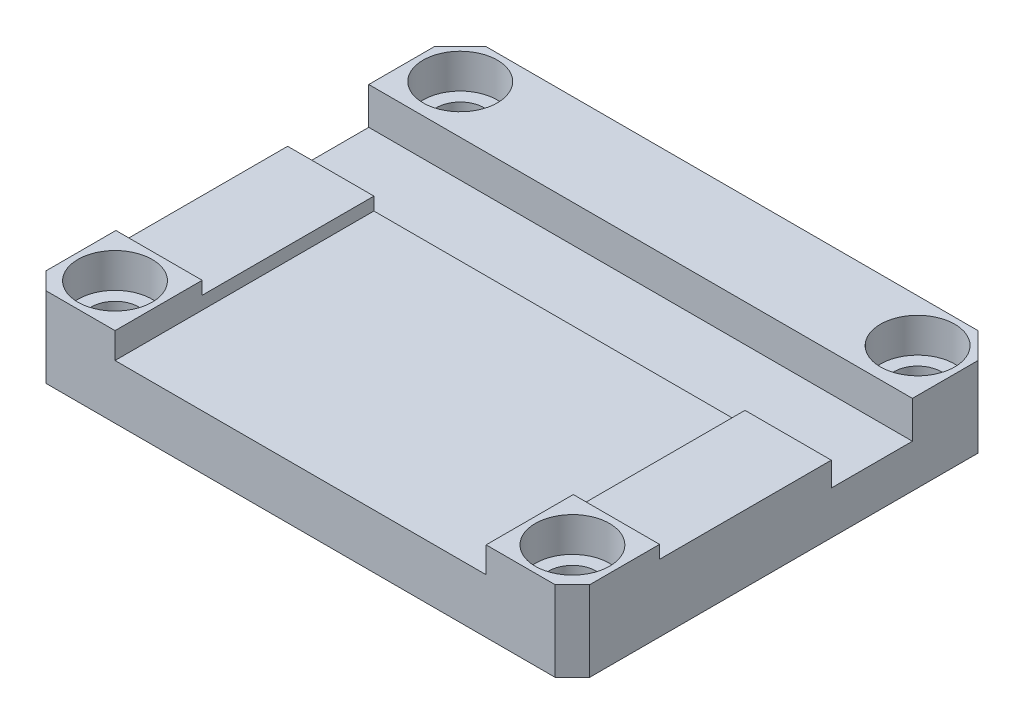
from build123d import *

# Parameters (mm, degrees)
SKETCH1_W                                           = 63
SKETCH1_H                                           = 50
BOSS_EXTRUDE1_DEPTH                                 = 9.3
CBORE_FOR_M5_HEX_SOCKET_HEAD_CAP_SCREW2_D           = 5.5
CBORE_FOR_M5_HEX_SOCKET_HEAD_CAP_SCREW2_CBORE_D     = 8.6
CBORE_FOR_M5_HEX_SOCKET_HEAD_CAP_SCREW2_CBORE_DEPTH = 4
CHAMFER1_SIZE                                       = 3
CHAMFER2_SIZE                                       = 2
CUT_EXTRUDE1_DEPTH                                  = 3
CUT_EXTRUDE2_DEPTH                                  = 4.3
SKETCH8_W                                           = 10
SKETCH8_H                                           = 19.9
CUT_EXTRUDE3_DEPTH                                  = 1.5


with BuildPart() as part:
    # Sketch1 → Boss-Extrude1 (new body)
    with BuildSketch(Plane(origin=(0, 0, 0), x_dir=(1, 0, 0), z_dir=(0, 1, 0))):
        Rectangle(SKETCH1_W, SKETCH1_H)
    extrude(amount=BOSS_EXTRUDE1_DEPTH)

    # CBORE for M5 Hex Socket Head Cap Screw2 (through all)
    with Locations(Plane(origin=(-26.5, 9.3, 20), x_dir=(0, 0, 1), z_dir=(0, 1, 0))):
        with Locations((0, 0), (0, 53), (-40, 53), (-40, 0)):
            CounterBoreHole(CBORE_FOR_M5_HEX_SOCKET_HEAD_CAP_SCREW2_D / 2, CBORE_FOR_M5_HEX_SOCKET_HEAD_CAP_SCREW2_CBORE_D / 2, CBORE_FOR_M5_HEX_SOCKET_HEAD_CAP_SCREW2_CBORE_DEPTH)

    # Chamfer1
    chamfer1_edges = [part.edges().sort_by_distance(p)[0] for p in [
        (-31.5, 4.65, -25),
        (31.5, 4.65, -25),
    ]]
    chamfer(chamfer1_edges, length=CHAMFER1_SIZE)

    # Chamfer2
    chamfer2_edges = [part.edges().sort_by_distance(p)[0] for p in [
        (31.5, 4.65, 25),
        (-31.5, 4.65, 25),
    ]]
    chamfer(chamfer2_edges, length=CHAMFER2_SIZE)

    # Sketch5 → Cut-Extrude1 (cut)
    with BuildSketch(Plane(origin=(0, 9.3, 0), x_dir=(1, 0, 0), z_dir=(0, 1, 0))):
        Polygon((0, -25), (-21.5, -25), (-21.5, 14.4), (21.5, 14.4), (21.5, -25), align=None)
    extrude(amount=-CUT_EXTRUDE1_DEPTH, mode=Mode.SUBTRACT)

    # Sketch7 → Cut-Extrude2 (cut)
    with BuildSketch(Plane(origin=(0, 9.3, 0), x_dir=(1, 0, 0), z_dir=(0, 1, 0))):
        Polygon((-21.5, 14.4), (31.5, 14.4), (31.5, 5), (-31.5, 5), (-31.5, 14.4), align=None)
    extrude(amount=-CUT_EXTRUDE2_DEPTH, mode=Mode.SUBTRACT)

    # Sketch8 → Cut-Extrude3 (cut)
    with BuildSketch(Plane(origin=(0, 9.3, 0), x_dir=(1, 0, 0), z_dir=(0, 1, 0))):
        with Locations((26.5, -4.95)):
            Rectangle(SKETCH8_W, SKETCH8_H)
        with Locations((-26.5, -4.95)):
            Rectangle(SKETCH8_W, SKETCH8_H)
    extrude(amount=-CUT_EXTRUDE3_DEPTH, mode=Mode.SUBTRACT)


solid = part.part
